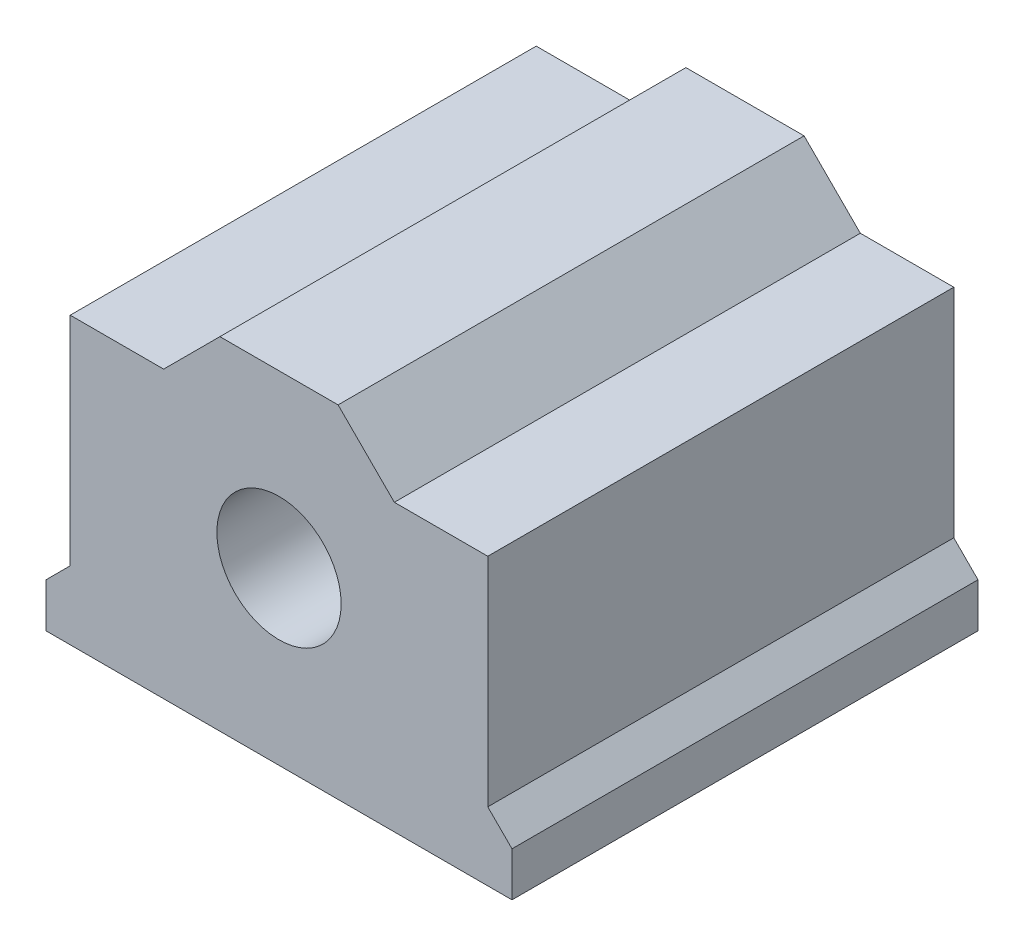
from build123d import *

# Parameters (mm, degrees)
SKETCH1_W           = 30
SKETCH1_H           = 30
BOSS_EXTRUDE1_DEPTH = 22
CUT_EXTRUDE1_DEPTH  = 48.791212581


with BuildPart() as part:
    # Sketch1 → Boss-Extrude1 (new body)
    with BuildSketch(Plane(origin=(0, 0, 0), x_dir=(1, 0, 0), z_dir=(0, 1, 0))):
        with Locations((15, 15)):
            Rectangle(SKETCH1_W, SKETCH1_H)
    extrude(amount=BOSS_EXTRUDE1_DEPTH)

    # Sketch2 → Cut-Extrude1 (cut, through all)
    with BuildSketch(Plane.XY):
        Polygon((7.574494777, 18.379095815), (11.195398962, 22), (0, 22), (0, 2.847414058), (1.559595822, 4.407009879), (1.559595822, 18.379095815), align=None)
        Polygon((30, 22), (18.804601038, 22), (22.425505223, 18.379095815), (28.440404178, 18.379095815), (28.440404178, 4.407009879), (30, 2.847414058), align=None)
        with BuildLine():
            ThreePointArc((19, 11), (17.828427125, 13.828427125), (15, 15))
            Line((15, 15), (15, 7))
            ThreePointArc((15, 7), (17.828427125, 8.171572875), (19, 11))
        make_face()
        with BuildLine():
            Line((15, 7), (15, 15))
            ThreePointArc((15, 15), (11, 11), (15, 7))
        make_face()
    extrude(amount=-CUT_EXTRUDE1_DEPTH, mode=Mode.SUBTRACT)


solid = part.part
